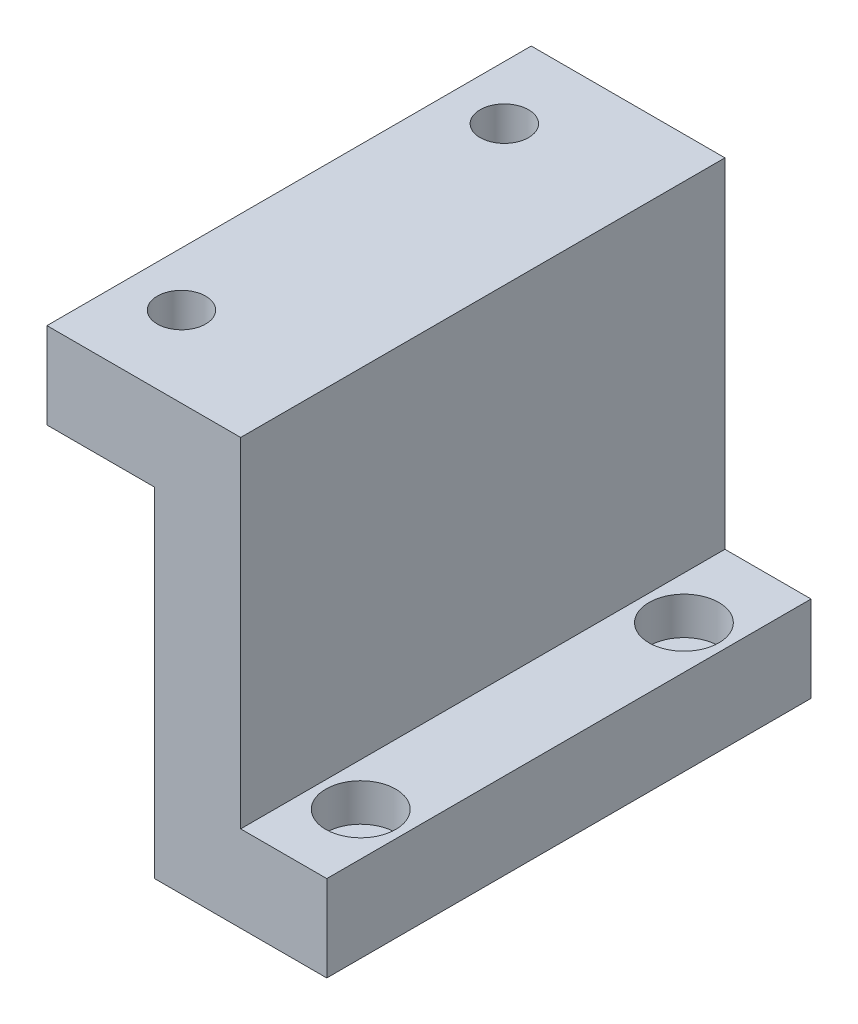
from build123d import *

# Parameters (mm, degrees)
BOSS_EXTRUDE1_DEPTH = 45
SKETCH2_R           = 2.25
CUT_EXTRUDE1_DEPTH  = 45
SKETCH3_R           = 1.7
CUT_EXTRUDE2_DEPTH  = 45
SKETCH4_R           = 3.25
CUT_EXTRUDE3_DEPTH  = 3.5


with BuildPart() as part:
    # Sketch1 → Boss-Extrude1 (new body)
    with BuildSketch(Plane.XY):
        Polygon((-4.588607595, 8.541139241), (13.411392405, 8.541139241), (13.411392405, -22.958860759), (21.411392405, -22.958860759), (21.411392405, -30.958860759), (5.411392405, -30.958860759), (5.411392405, 0.541139241), (-4.588607595, 0.541139241), align=None)
    extrude(amount=BOSS_EXTRUDE1_DEPTH)

    # Sketch2 → Cut-Extrude1 (cut)
    with BuildSketch(Plane(origin=(0, 8.541139241, 0), x_dir=(1, 0, 0), z_dir=(0, 1, 0))):
        with Locations((0.411392405, -7.5)):
            Circle(SKETCH2_R)
        with Locations((0.411392405, -37.5)):
            Circle(SKETCH2_R)
    extrude(amount=-CUT_EXTRUDE1_DEPTH, mode=Mode.SUBTRACT)

    # Sketch3 → Cut-Extrude2 (cut)
    with BuildSketch(Plane(origin=(0, -22.958860759, 0), x_dir=(1, 0, 0), z_dir=(0, 1, 0))):
        with Locations((17.411392405, -7.810599517)):
            Circle(SKETCH3_R)
        with Locations((17.411392405, -37.843221269)):
            Circle(SKETCH3_R)
    extrude(amount=-CUT_EXTRUDE2_DEPTH, mode=Mode.SUBTRACT)

    # Sketch4 → Cut-Extrude3 (cut)
    with BuildSketch(Plane(origin=(0, -22.958860759, 0), x_dir=(1, 0, 0), z_dir=(0, 1, 0))):
        with Locations((17.411392405, -7.810599517)):
            Circle(SKETCH4_R)
        with Locations((17.411392405, -37.843221269)):
            Circle(SKETCH4_R)
    extrude(amount=-CUT_EXTRUDE3_DEPTH, mode=Mode.SUBTRACT)


solid = part.part
